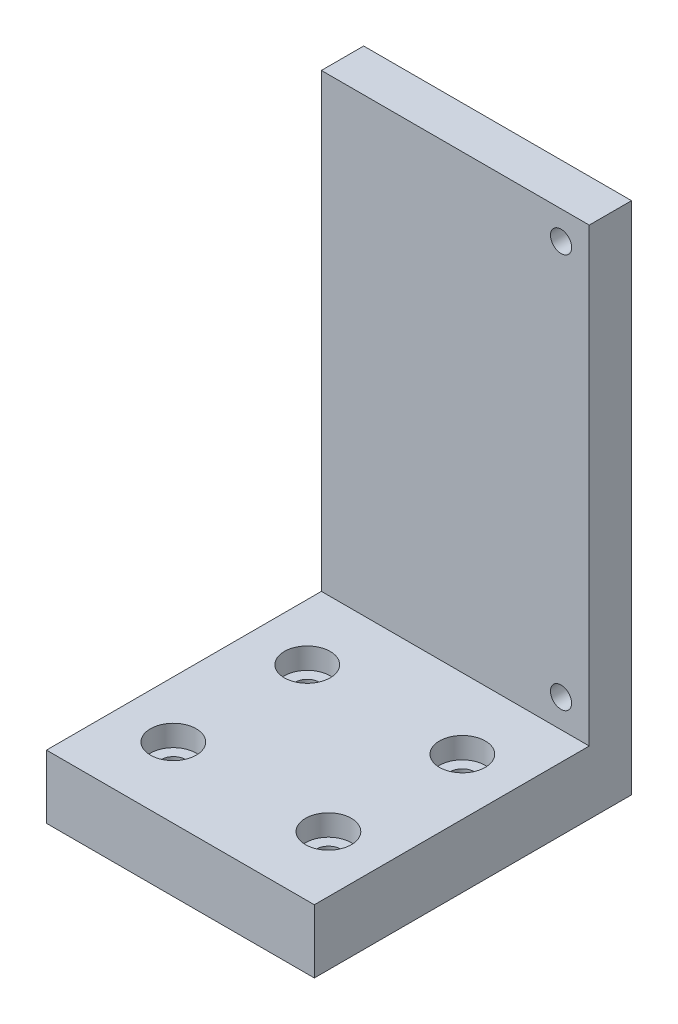
from build123d import *

# Parameters (mm, degrees)
SKETCH1_W                      = 38
SKETCH1_H                      = 45
BOSS_EXTRUDE2_DEPTH            = 9
SKETCH2_W                      = 38
SKETCH2_H                      = 6
BOSS_EXTRUDE3_DEPTH            = 64
SKETCH3_R                      = 1.5
CUT_EXTRUDE1_DEPTH             = 64
CBORE_FOR_M3_SHCS1_D           = 3.4
CBORE_FOR_M3_SHCS1_CBORE_D     = 6.5
CBORE_FOR_M3_SHCS1_CBORE_DEPTH = 3


with BuildPart() as part:
    # Sketch1 → Boss-Extrude2 (new body)
    with BuildSketch(Plane(origin=(0, 0, 0), x_dir=(1, 0, 0), z_dir=(0, 1, 0))):
        with Locations((19, 22.5)):
            Rectangle(SKETCH1_W, SKETCH1_H)
    extrude(amount=BOSS_EXTRUDE2_DEPTH)

    # Sketch2 → Boss-Extrude3 (add)
    with BuildSketch(Plane(origin=(0, 9, 0), x_dir=(1, 0, 0), z_dir=(0, 1, 0))):
        with Locations((19, 42)):
            Rectangle(SKETCH2_W, SKETCH2_H)
    extrude(amount=BOSS_EXTRUDE3_DEPTH)

    # Sketch3 → Cut-Extrude1 (cut)
    with BuildSketch(Plane.XY.offset(-39)):
        with Locations((34, 69)):
            Circle(SKETCH3_R)
        with Locations((34, 13)):
            Circle(SKETCH3_R)
    extrude(amount=-CUT_EXTRUDE1_DEPTH, mode=Mode.SUBTRACT)

    # CBORE for M3 SHCS1 (through all)
    with Locations(Plane(origin=(0, 9, 0), x_dir=(1, 0, 0), z_dir=(0, 1, 0))):
        with Locations((8, 29), (8, 10), (30, 10), (30, 29)):
            CounterBoreHole(CBORE_FOR_M3_SHCS1_D / 2, CBORE_FOR_M3_SHCS1_CBORE_D / 2, CBORE_FOR_M3_SHCS1_CBORE_DEPTH)


solid = part.part
